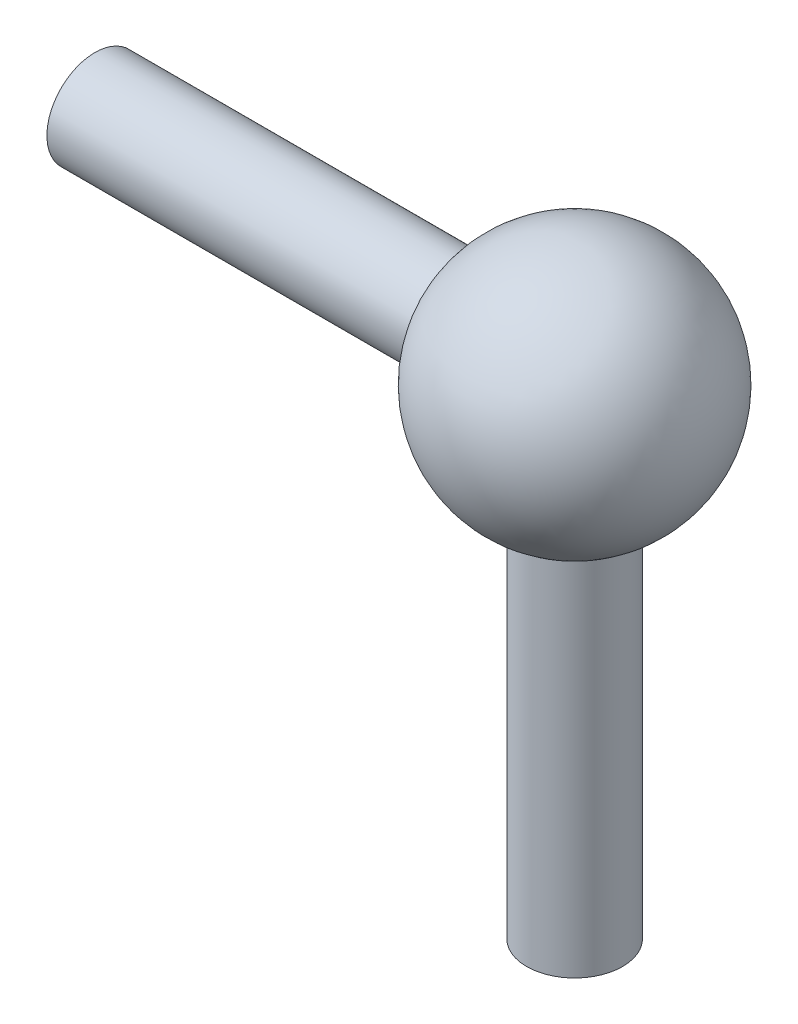
from build123d import *

# Parameters (mm, degrees)
SKETCH_3_R      = 2.5
EXTRUDE_2_DEPTH = 25
SKETCH_2_R      = 2.5
EXTRUDE_1_DEPTH = 25


with BuildPart() as part:
    # 스케치1 → 회전1 (revolve)
    with BuildSketch(Plane.XY):
        with BuildLine():
            Line((0, -6.5), (0, 6.5))
            ThreePointArc((0, 6.5), (-6.5, 0), (0, -6.5))
        make_face()
    revolve(axis=Axis((0, 7.642806544, 0), (0, -1, 0)))

    # 스케치3 → 보스-돌출2 (add)
    with BuildSketch(Plane(origin=(0, 0, 0), x_dir=(0, 0, -1), z_dir=(1, 0, 0))):
        Circle(SKETCH_3_R)
    extrude(amount=-EXTRUDE_2_DEPTH)

    # 스케치2 → 보스-돌출1 (add)
    with BuildSketch(Plane(origin=(0, 0, 0), x_dir=(1, 0, 0), z_dir=(0, 1, 0))):
        Circle(SKETCH_2_R)
    extrude(amount=-EXTRUDE_1_DEPTH)


solid = part.part
